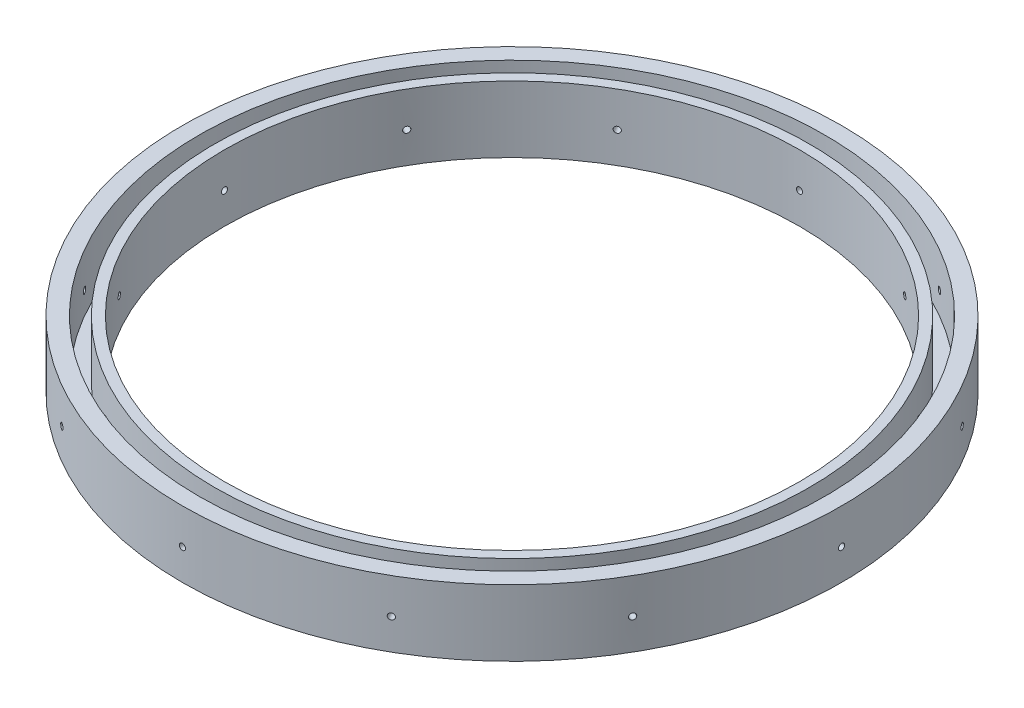
from build123d import *

# Parameters (mm, degrees)
SKETCH1_R           = 94.615
SKETCH1_R_2         = 82.55
BOSS_EXTRUDE1_DEPTH = 19.05
SKETCH2_R           = 89.8525
SKETCH2_R_2         = 85.4075
CUT_EXTRUDE1_DEPTH  = 16.51
CUT_EXTRUDE2_START  = -94.615
SKETCH3_R           = 0.8750046
CUT_EXTRUDE2_DEPTH  = 12.069638
CIRPATTERN1_COUNT   = 12


with BuildPart() as part:
    # Sketch1 → Boss-Extrude1 (new body)
    with BuildSketch(Plane(origin=(0, 0, 0), x_dir=(1, 0, 0), z_dir=(0, 1, 0))):
        Circle(SKETCH1_R)
        Circle(SKETCH1_R_2, mode=Mode.SUBTRACT)
    extrude(amount=BOSS_EXTRUDE1_DEPTH)

    # Sketch2 → Cut-Extrude1 (cut)
    with BuildSketch(Plane(origin=(0, 19.05, 0), x_dir=(1, 0, 0), z_dir=(0, 1, 0))):
        Circle(SKETCH2_R)
        Circle(SKETCH2_R_2, mode=Mode.SUBTRACT)
    extrude(amount=-CUT_EXTRUDE1_DEPTH, mode=Mode.SUBTRACT)

    # Sketch3 → Cut-Extrude2 (cut)
    with BuildSketch(Plane.XY.offset(CUT_EXTRUDE2_START)):
        with Locations((0, 8.89)):
            Circle(SKETCH3_R)
    cut_extrude2 = extrude(amount=CUT_EXTRUDE2_DEPTH, mode=Mode.SUBTRACT)

    # CirPattern1: Cut-Extrude2 ×12 about axis
    cirpattern1_axis = Axis((0, 19.05, 0), (0, 1, 0))
    for i in range(1, CIRPATTERN1_COUNT):
        add(cut_extrude2.rotate(cirpattern1_axis, i * 360 / CIRPATTERN1_COUNT), mode=Mode.SUBTRACT)


solid = part.part
